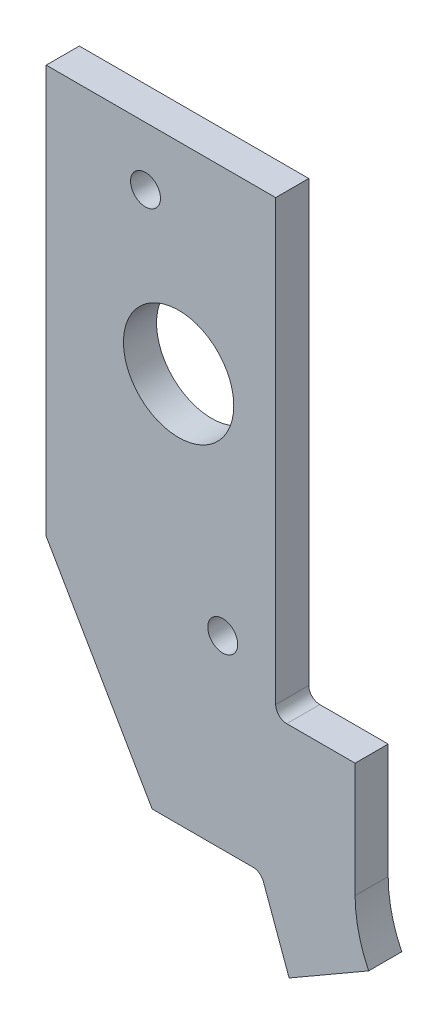
from build123d import *

# Parameters (mm, degrees)
BOSS_EXTRUDE1_DEPTH          = 4.7625
F_6_CLEARANCE_HOLE1_D        = 4.3053
F_5_8_0_625_DIAMETER_HOLE1_D = 15.875


with BuildPart() as part:
    # Sketch1 → Boss-Extrude1 (new body)
    with BuildSketch(Plane.XY):
        with BuildLine():
            Line((-3163.88635614, 1099.09115169), (-3160.187774322, 1088.929381663))
            Line((-3160.187774322, 1088.929381663), (-3148.734838552, 1095.541737213))
            ThreePointArc((-3148.734838552, 1095.541737213), (-3150.193848799, 1099.631639206), (-3150.688757178, 1103.945694712))
            Line((-3150.688757178, 1103.945694712), (-3150.688757178, 1120.455694712))
            Line((-3150.688757178, 1120.455694712), (-3160.531257178, 1120.455694712))
            ThreePointArc((-3160.531257178, 1120.455694712), (-3161.653789193, 1120.920662697), (-3162.118757178, 1122.043194712))
            Line((-3162.118757178, 1122.043194712), (-3162.118757178, 1185.225694712))
            Line((-3162.118757178, 1185.225694712), (-3195.138757178, 1185.225694712))
            Line((-3195.138757178, 1185.225694712), (-3195.138757178, 1126.488194712))
            Line((-3195.138757178, 1126.488194712), (-3179.898757178, 1100.135694712))
            Line((-3179.898757178, 1100.135694712), (-3165.378118175, 1100.135694712))
            ThreePointArc((-3165.378118175, 1100.135694712), (-3164.467565582, 1099.848598583), (-3163.88635614, 1099.09115169))
        make_face()
    extrude(amount=BOSS_EXTRUDE1_DEPTH)

    # #6 Clearance Hole1 (through all)
    with Locations(Plane.XY.offset(4.7625)):
        with Locations((-3169.738757178, 1126.805694712), (-3180.851257178, 1176.843694712)):
            Hole(F_6_CLEARANCE_HOLE1_D / 2)

    # 5/8 (0.625) Diameter Hole1 (through all)
    with Locations(Plane.XY.offset(4.7625)):
        with Locations((-3176.088757178, 1156.269694712)):
            Hole(F_5_8_0_625_DIAMETER_HOLE1_D / 2)


solid = part.part
